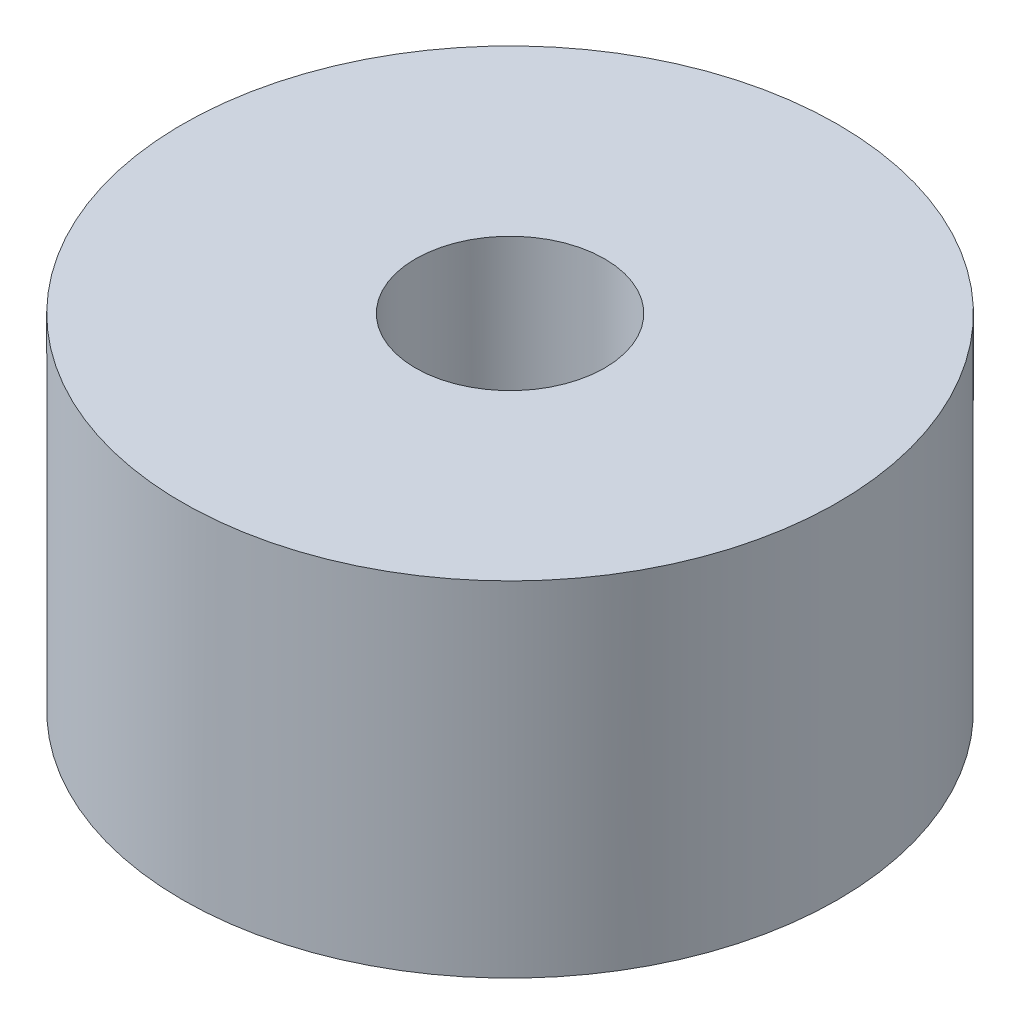
from build123d import *

# Parameters (mm, degrees)
SKETCH2_R               = 9.525
BOSS_EXTRUDE1_DEPTH     = 1
M5_CLEARANCE_HOLE1_D    = 5.5
CUT_EXTRUDE1_DEPTH      = 1
CUT_EXTRUDE1_DEPTH_BACK = 2
SKETCH9_R               = 9.525
SKETCH9_R_2             = 2.75
BOSS_EXTRUDE2_DEPTH     = 10


with BuildPart() as part:
    # Sketch2 → Boss-Extrude1 (new body)
    with BuildSketch(Plane(origin=(0, 0, 0), x_dir=(1, 0, 0), z_dir=(0, 1, 0))):
        Circle(SKETCH2_R)
    extrude(amount=BOSS_EXTRUDE1_DEPTH)

    # M5 Clearance Hole1 (through all)
    with Locations(Plane(origin=(0, 1, 0), x_dir=(1, 0, 0), z_dir=(0, 1, 0))):
        with Locations((0, 0)):
            Hole(M5_CLEARANCE_HOLE1_D / 2)

    # Sketch7 → Cut-Extrude1 (cut, two sides)
    with BuildSketch(Plane(origin=(0, 1, 0), x_dir=(1, 0, 0), z_dir=(0, 1, 0))) as cut_extrude1_sk:
        Polygon((3.063849251, 9.018783331), (-3.927822903, 8.677432353), (-3.960317229, 9.342992692), (3.031354925, 9.68434367), align=None)
    extrude(amount=CUT_EXTRUDE1_DEPTH, mode=Mode.SUBTRACT)
    extrude(cut_extrude1_sk.sketch, amount=-CUT_EXTRUDE1_DEPTH_BACK, mode=Mode.SUBTRACT)

    # Sketch9 → Boss-Extrude2 (add)
    with BuildSketch(Plane.XZ):
        Circle(SKETCH9_R)
        Circle(SKETCH9_R_2, mode=Mode.SUBTRACT)
    extrude(amount=-BOSS_EXTRUDE2_DEPTH)


solid = part.part
